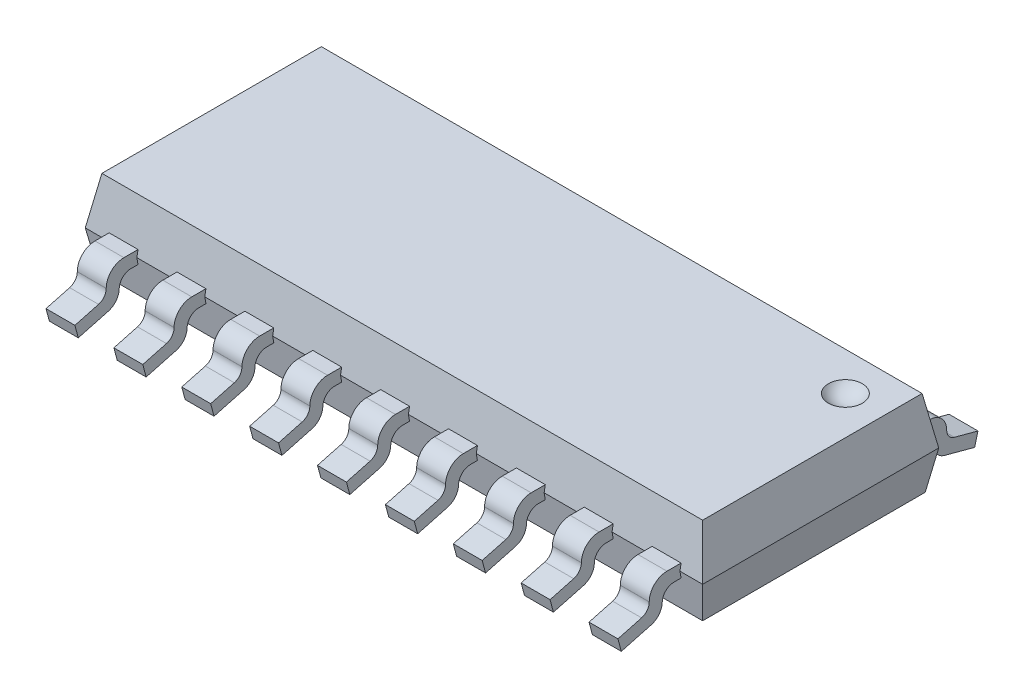
from build123d import *

# Parameters (mm, degrees)
BOSS_EXTRUDE1_DEPTH  = 5.23
CUT_EXTRUDE1_DEPTH   = 4.375
BOSS_EXTRUDE3_DEPTH  = 0.245
LPATTERN1_COUNT      = 5
LPATTERN1_PITCH      = 1.15
LPATTERN1_COL_COUNT  = 5
LPATTERN1_COL_PITCH  = 1.15
MIRROR1_COPY_1_DEPTH = 0.245
MIRROR1_COPY_2_DEPTH = 0.245
MIRROR1_COPY_3_DEPTH = 0.245
MIRROR1_COPY_4_DEPTH = 0.245
MIRROR1_COPY_5_DEPTH = 0.245
MIRROR1_COPY_6_DEPTH = 0.245
MIRROR1_COPY_7_DEPTH = 0.245
MIRROR1_COPY_8_DEPTH = 0.245


with BuildPart() as part:
    # Sketch3 → Boss-Extrude1 (new body, symmetric)
    with BuildSketch(Plane(origin=(0, 0, 0), x_dir=(0, 0, -1), z_dir=(1, 0, 0))):
        Polygon((-2, 0), (-1.885387463, -0.65), (1.885387463, -0.65), (2, 0), (1.858938415, 0.8), (-1.858938415, 0.8), align=None)
    extrude(amount=BOSS_EXTRUDE1_DEPTH, both=True)

    # Sketch4 → Cut-Extrude1 (cut, symmetric)
    with BuildSketch(Plane.XY):
        Polygon((-5.23, 0), (-5.088938415, 0.8), (-6, 0.8), (-6, -0.65), (-5.115387463, -0.65), align=None)
        Polygon((6, -0.65), (6, 0.8), (5.088938415, 0.8), (5.23, 0), (5.115387463, -0.65), align=None)
    extrude(amount=CUT_EXTRUDE1_DEPTH, both=True, mode=Mode.SUBTRACT)

    # Sketch8 → Boss-Extrude3 (add, symmetric)
    with BuildSketch(Plane(origin=(0, 0, 0), x_dir=(0, 0, -1), z_dir=(1, 0, 0))):
        with BuildLine():
            Line((-2, 0), (-1.980604032, 0.11))
            Line((-1.980604032, 0.11), (-2.22, 0.11))
            ThreePointArc((-2.22, 0.11), (-2.432132034, 0.022132034), (-2.52, -0.19))
            Line((-2.52, -0.19), (-2.52, -0.191271738))
            ThreePointArc((-2.52, -0.191271738), (-2.556144122, -0.297748886), (-2.649638362, -0.360219741))
            Line((-2.649638362, -0.360219741), (-3.05, -0.467496318))
            Line((-3.05, -0.467496318), (-2.99305981, -0.68))
            Line((-2.99305981, -0.68), (-2.485295239, -0.543944893))
            ThreePointArc((-2.485295239, -0.543944893), (-2.351661665, -0.454653794), (-2.3, -0.302463437))
            Line((-2.3, -0.302463437), (-2.3, -0.31))
            ThreePointArc((-2.3, -0.31), (-2.241421356, -0.168578644), (-2.1, -0.11))
            Line((-2.1, -0.11), (-1.980604032, -0.11))
            Line((-1.980604032, -0.11), (-2, 0))
        make_face()
    boss_extrude3 = extrude(amount=BOSS_EXTRUDE3_DEPTH, both=True)

    # Sketch9 → Cut-Revolve1 (revolve, cut)
    with BuildSketch(Plane(origin=(0, 1, 0), x_dir=(1, 0, 0), z_dir=(0, 1, 0))):
        with BuildLine():
            Line((4.788938415, 1.208938415), (4.088938415, 1.208938415))
            ThreePointArc((4.088938415, 1.208938415), (4.438938415, 1.558938415), (4.788938415, 1.208938415))
        make_face()
    revolve(axis=Axis((4.788938415, 1, -1.208938415), (-1, 0, 0)), mode=Mode.SUBTRACT)

    # LPattern1: Boss-Extrude3 ×5
    with Locations(*[(i * LPATTERN1_PITCH, 0, 0) for i in range(1, LPATTERN1_COUNT)]):
        add(boss_extrude3)

    # LPattern1 col: Boss-Extrude3 ×5
    with Locations(*[(-i * LPATTERN1_COL_PITCH, 0, 0) for i in range(1, LPATTERN1_COL_COUNT)]):
        add(boss_extrude3)

    # Mirror1: Boss-Extrude3 across plane
    add(boss_extrude3.mirror(Plane.XY))

    # Mirror1 copy 1 sketch → Mirror1 copy 1 (add, symmetric)
    with BuildSketch(Plane(origin=(1.15, 0, 0), x_dir=(0, 0, 1), z_dir=(1, 0, 0))):
        with BuildLine():
            Line((-2, 0), (-1.980604032, -0.11))
            Line((-1.980604032, -0.11), (-2.22, -0.11))
            ThreePointArc((-2.22, -0.11), (-2.432132034, -0.022132034), (-2.52, 0.19))
            Line((-2.52, 0.19), (-2.52, 0.191271738))
            ThreePointArc((-2.52, 0.191271738), (-2.556144122, 0.297748886), (-2.649638362, 0.360219741))
            Line((-2.649638362, 0.360219741), (-3.05, 0.467496318))
            Line((-3.05, 0.467496318), (-2.99305981, 0.68))
            Line((-2.99305981, 0.68), (-2.485295239, 0.543944893))
            ThreePointArc((-2.485295239, 0.543944893), (-2.351661665, 0.454653794), (-2.3, 0.302463437))
            Line((-2.3, 0.302463437), (-2.3, 0.31))
            ThreePointArc((-2.3, 0.31), (-2.241421356, 0.168578644), (-2.1, 0.11))
            Line((-2.1, 0.11), (-1.980604032, 0.11))
            Line((-1.980604032, 0.11), (-2, 0))
        make_face()
    extrude(amount=MIRROR1_COPY_1_DEPTH, both=True)

    # Mirror1 copy 2 sketch → Mirror1 copy 2 (add, symmetric)
    with BuildSketch(Plane(origin=(2.3, 0, 0), x_dir=(0, 0, 1), z_dir=(1, 0, 0))):
        with BuildLine():
            Line((-2, 0), (-1.980604032, -0.11))
            Line((-1.980604032, -0.11), (-2.22, -0.11))
            ThreePointArc((-2.22, -0.11), (-2.432132034, -0.022132034), (-2.52, 0.19))
            Line((-2.52, 0.19), (-2.52, 0.191271738))
            ThreePointArc((-2.52, 0.191271738), (-2.556144122, 0.297748886), (-2.649638362, 0.360219741))
            Line((-2.649638362, 0.360219741), (-3.05, 0.467496318))
            Line((-3.05, 0.467496318), (-2.99305981, 0.68))
            Line((-2.99305981, 0.68), (-2.485295239, 0.543944893))
            ThreePointArc((-2.485295239, 0.543944893), (-2.351661665, 0.454653794), (-2.3, 0.302463437))
            Line((-2.3, 0.302463437), (-2.3, 0.31))
            ThreePointArc((-2.3, 0.31), (-2.241421356, 0.168578644), (-2.1, 0.11))
            Line((-2.1, 0.11), (-1.980604032, 0.11))
            Line((-1.980604032, 0.11), (-2, 0))
        make_face()
    extrude(amount=MIRROR1_COPY_2_DEPTH, both=True)

    # Mirror1 copy 3 sketch → Mirror1 copy 3 (add, symmetric)
    with BuildSketch(Plane(origin=(3.45, 0, 0), x_dir=(0, 0, 1), z_dir=(1, 0, 0))):
        with BuildLine():
            Line((-2, 0), (-1.980604032, -0.11))
            Line((-1.980604032, -0.11), (-2.22, -0.11))
            ThreePointArc((-2.22, -0.11), (-2.432132034, -0.022132034), (-2.52, 0.19))
            Line((-2.52, 0.19), (-2.52, 0.191271738))
            ThreePointArc((-2.52, 0.191271738), (-2.556144122, 0.297748886), (-2.649638362, 0.360219741))
            Line((-2.649638362, 0.360219741), (-3.05, 0.467496318))
            Line((-3.05, 0.467496318), (-2.99305981, 0.68))
            Line((-2.99305981, 0.68), (-2.485295239, 0.543944893))
            ThreePointArc((-2.485295239, 0.543944893), (-2.351661665, 0.454653794), (-2.3, 0.302463437))
            Line((-2.3, 0.302463437), (-2.3, 0.31))
            ThreePointArc((-2.3, 0.31), (-2.241421356, 0.168578644), (-2.1, 0.11))
            Line((-2.1, 0.11), (-1.980604032, 0.11))
            Line((-1.980604032, 0.11), (-2, 0))
        make_face()
    extrude(amount=MIRROR1_COPY_3_DEPTH, both=True)

    # Mirror1 copy 4 sketch → Mirror1 copy 4 (add, symmetric)
    with BuildSketch(Plane(origin=(4.6, 0, 0), x_dir=(0, 0, 1), z_dir=(1, 0, 0))):
        with BuildLine():
            Line((-2, 0), (-1.980604032, -0.11))
            Line((-1.980604032, -0.11), (-2.22, -0.11))
            ThreePointArc((-2.22, -0.11), (-2.432132034, -0.022132034), (-2.52, 0.19))
            Line((-2.52, 0.19), (-2.52, 0.191271738))
            ThreePointArc((-2.52, 0.191271738), (-2.556144122, 0.297748886), (-2.649638362, 0.360219741))
            Line((-2.649638362, 0.360219741), (-3.05, 0.467496318))
            Line((-3.05, 0.467496318), (-2.99305981, 0.68))
            Line((-2.99305981, 0.68), (-2.485295239, 0.543944893))
            ThreePointArc((-2.485295239, 0.543944893), (-2.351661665, 0.454653794), (-2.3, 0.302463437))
            Line((-2.3, 0.302463437), (-2.3, 0.31))
            ThreePointArc((-2.3, 0.31), (-2.241421356, 0.168578644), (-2.1, 0.11))
            Line((-2.1, 0.11), (-1.980604032, 0.11))
            Line((-1.980604032, 0.11), (-2, 0))
        make_face()
    extrude(amount=MIRROR1_COPY_4_DEPTH, both=True)

    # Mirror1 copy 5 sketch → Mirror1 copy 5 (add, symmetric)
    with BuildSketch(Plane(origin=(-1.15, 0, 0), x_dir=(0, 0, 1), z_dir=(1, 0, 0))):
        with BuildLine():
            Line((-2, 0), (-1.980604032, -0.11))
            Line((-1.980604032, -0.11), (-2.22, -0.11))
            ThreePointArc((-2.22, -0.11), (-2.432132034, -0.022132034), (-2.52, 0.19))
            Line((-2.52, 0.19), (-2.52, 0.191271738))
            ThreePointArc((-2.52, 0.191271738), (-2.556144122, 0.297748886), (-2.649638362, 0.360219741))
            Line((-2.649638362, 0.360219741), (-3.05, 0.467496318))
            Line((-3.05, 0.467496318), (-2.99305981, 0.68))
            Line((-2.99305981, 0.68), (-2.485295239, 0.543944893))
            ThreePointArc((-2.485295239, 0.543944893), (-2.351661665, 0.454653794), (-2.3, 0.302463437))
            Line((-2.3, 0.302463437), (-2.3, 0.31))
            ThreePointArc((-2.3, 0.31), (-2.241421356, 0.168578644), (-2.1, 0.11))
            Line((-2.1, 0.11), (-1.980604032, 0.11))
            Line((-1.980604032, 0.11), (-2, 0))
        make_face()
    extrude(amount=MIRROR1_COPY_5_DEPTH, both=True)

    # Mirror1 copy 6 sketch → Mirror1 copy 6 (add, symmetric)
    with BuildSketch(Plane(origin=(-2.3, 0, 0), x_dir=(0, 0, 1), z_dir=(1, 0, 0))):
        with BuildLine():
            Line((-2, 0), (-1.980604032, -0.11))
            Line((-1.980604032, -0.11), (-2.22, -0.11))
            ThreePointArc((-2.22, -0.11), (-2.432132034, -0.022132034), (-2.52, 0.19))
            Line((-2.52, 0.19), (-2.52, 0.191271738))
            ThreePointArc((-2.52, 0.191271738), (-2.556144122, 0.297748886), (-2.649638362, 0.360219741))
            Line((-2.649638362, 0.360219741), (-3.05, 0.467496318))
            Line((-3.05, 0.467496318), (-2.99305981, 0.68))
            Line((-2.99305981, 0.68), (-2.485295239, 0.543944893))
            ThreePointArc((-2.485295239, 0.543944893), (-2.351661665, 0.454653794), (-2.3, 0.302463437))
            Line((-2.3, 0.302463437), (-2.3, 0.31))
            ThreePointArc((-2.3, 0.31), (-2.241421356, 0.168578644), (-2.1, 0.11))
            Line((-2.1, 0.11), (-1.980604032, 0.11))
            Line((-1.980604032, 0.11), (-2, 0))
        make_face()
    extrude(amount=MIRROR1_COPY_6_DEPTH, both=True)

    # Mirror1 copy 7 sketch → Mirror1 copy 7 (add, symmetric)
    with BuildSketch(Plane(origin=(-3.45, 0, 0), x_dir=(0, 0, 1), z_dir=(1, 0, 0))):
        with BuildLine():
            Line((-2, 0), (-1.980604032, -0.11))
            Line((-1.980604032, -0.11), (-2.22, -0.11))
            ThreePointArc((-2.22, -0.11), (-2.432132034, -0.022132034), (-2.52, 0.19))
            Line((-2.52, 0.19), (-2.52, 0.191271738))
            ThreePointArc((-2.52, 0.191271738), (-2.556144122, 0.297748886), (-2.649638362, 0.360219741))
            Line((-2.649638362, 0.360219741), (-3.05, 0.467496318))
            Line((-3.05, 0.467496318), (-2.99305981, 0.68))
            Line((-2.99305981, 0.68), (-2.485295239, 0.543944893))
            ThreePointArc((-2.485295239, 0.543944893), (-2.351661665, 0.454653794), (-2.3, 0.302463437))
            Line((-2.3, 0.302463437), (-2.3, 0.31))
            ThreePointArc((-2.3, 0.31), (-2.241421356, 0.168578644), (-2.1, 0.11))
            Line((-2.1, 0.11), (-1.980604032, 0.11))
            Line((-1.980604032, 0.11), (-2, 0))
        make_face()
    extrude(amount=MIRROR1_COPY_7_DEPTH, both=True)

    # Mirror1 copy 8 sketch → Mirror1 copy 8 (add, symmetric)
    with BuildSketch(Plane(origin=(-4.6, 0, 0), x_dir=(0, 0, 1), z_dir=(1, 0, 0))):
        with BuildLine():
            Line((-2, 0), (-1.980604032, -0.11))
            Line((-1.980604032, -0.11), (-2.22, -0.11))
            ThreePointArc((-2.22, -0.11), (-2.432132034, -0.022132034), (-2.52, 0.19))
            Line((-2.52, 0.19), (-2.52, 0.191271738))
            ThreePointArc((-2.52, 0.191271738), (-2.556144122, 0.297748886), (-2.649638362, 0.360219741))
            Line((-2.649638362, 0.360219741), (-3.05, 0.467496318))
            Line((-3.05, 0.467496318), (-2.99305981, 0.68))
            Line((-2.99305981, 0.68), (-2.485295239, 0.543944893))
            ThreePointArc((-2.485295239, 0.543944893), (-2.351661665, 0.454653794), (-2.3, 0.302463437))
            Line((-2.3, 0.302463437), (-2.3, 0.31))
            ThreePointArc((-2.3, 0.31), (-2.241421356, 0.168578644), (-2.1, 0.11))
            Line((-2.1, 0.11), (-1.980604032, 0.11))
            Line((-1.980604032, 0.11), (-2, 0))
        make_face()
    extrude(amount=MIRROR1_COPY_8_DEPTH, both=True)


solid = part.part
